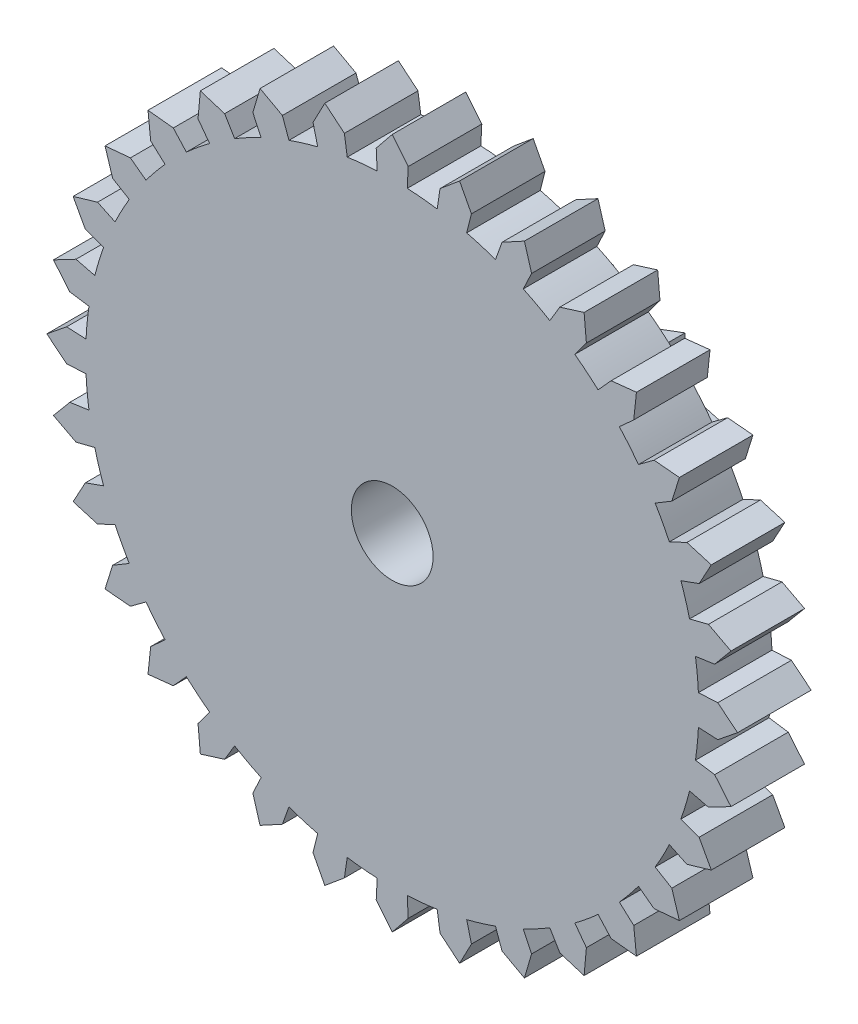
from build123d import *

# Parameters (mm, degrees)
SKETCH1_R           = 1
BOSS_EXTRUDE1_DEPTH = 1.8
SKETCH2_R           = 1
BOSS_EXTRUDE2_DEPTH = 3.6


with BuildPart() as part:
    # Sketch1 → Boss-Extrude1 (new body)
    with BuildSketch(Plane.XY):
        with BuildLine():
            Line((1.937766935, 7.735999244), (1.648513221, 8.287635619))
            Line((1.648513221, 8.287635619), (1.170175534, 7.888682667))
            Line((1.170175534, 7.888682667), (1.100478558, 7.418823825))
            ThreePointArc((1.100478558, 7.418823825), (0.918080064, 7.443596509), (0.735128552, 7.46388545))
            ThreePointArc((0.735128552, 7.46388545), (0.551734227, 7.479678425), (0.368007557, 7.490965922))
            Line((0.368007557, 7.490965922), (0.391314703, 7.965393763))
            Line((0.391314703, 7.965393763), (0, 8.45))
            Line((0, 8.45), (-0.391314703, 7.965393763))
            Line((-0.391314703, 7.965393763), (-0.368007557, 7.490965922))
            ThreePointArc((-0.368007557, 7.490965922), (-0.551734227, 7.479678425), (-0.735128552, 7.46388545))
            ThreePointArc((-0.735128552, 7.46388545), (-0.918080064, 7.443596509), (-1.100478558, 7.418823825))
            Line((-1.100478558, 7.418823825), (-1.170175534, 7.888682667))
            Line((-1.170175534, 7.888682667), (-1.648513221, 8.287635619))
            Line((-1.648513221, 8.287635619), (-1.937766935, 7.735999244))
            Line((-1.937766935, 7.735999244), (-1.822351349, 7.275234399))
            ThreePointArc((-1.822351349, 7.275234399), (-2.000345681, 7.228320493), (-2.177135079, 7.177052518))
            ThreePointArc((-2.177135079, 7.177052518), (-2.352613053, 7.121461354), (-2.5266739, 7.061580489))
            Line((-2.5266739, 7.061580489), (-2.686696581, 7.50881392))
            Line((-2.686696581, 7.50881392), (-3.233675003, 7.80678205))
            Line((-3.233675003, 7.80678205), (-3.40975187, 7.209314613))
            Line((-3.40975187, 7.209314613), (-3.206663201, 6.779919698))
            ThreePointArc((-3.206663201, 6.779919698), (-3.372084972, 6.699182259), (-3.535475526, 6.614409483))
            ThreePointArc((-3.535475526, 6.614409483), (-3.696736442, 6.525652433), (-3.855770581, 6.432964575))
            Line((-3.855770581, 6.432964575), (-4.099969385, 6.840385665))
            Line((-4.099969385, 6.840385665), (-4.694568469, 7.025918224))
            Line((-4.694568469, 7.025918224), (-4.750701953, 6.405580064))
            Line((-4.750701953, 6.405580064), (-4.467744784, 6.024056486))
            ThreePointArc((-4.467744784, 6.024056486), (-4.614236929, 5.912598207), (-4.757949631, 5.7975784))
            ThreePointArc((-4.757949631, 5.7975784), (-4.898796322, 5.679066349), (-5.036692161, 5.55713344))
            Line((-5.036692161, 5.55713344), (-5.355682665, 5.909085225))
            Line((-5.355682665, 5.909085225), (-5.975052301, 5.975052301))
            Line((-5.975052301, 5.975052301), (-5.909085225, 5.355682665))
            Line((-5.909085225, 5.355682665), (-5.55713344, 5.036692161))
            ThreePointArc((-5.55713344, 5.036692161), (-5.679066349, 4.898796322), (-5.7975784, 4.757949631))
            ThreePointArc((-5.7975784, 4.757949631), (-5.912598207, 4.614236929), (-6.024056486, 4.467744784))
            Line((-6.024056486, 4.467744784), (-6.405580064, 4.750701953))
            Line((-6.405580064, 4.750701953), (-7.025918224, 4.694568469))
            Line((-7.025918224, 4.694568469), (-6.840385665, 4.099969385))
            Line((-6.840385665, 4.099969385), (-6.432964575, 3.855770581))
            ThreePointArc((-6.432964575, 3.855770581), (-6.525652433, 3.696736442), (-6.614409483, 3.535475526))
            ThreePointArc((-6.614409483, 3.535475526), (-6.699182259, 3.372084972), (-6.779919698, 3.206663201))
            Line((-6.779919698, 3.206663201), (-7.209314613, 3.40975187))
            Line((-7.209314613, 3.40975187), (-7.80678205, 3.233675003))
            Line((-7.80678205, 3.233675003), (-7.50881392, 2.686696581))
            Line((-7.50881392, 2.686696581), (-7.061580489, 2.5266739))
            ThreePointArc((-7.061580489, 2.5266739), (-7.121461354, 2.352613053), (-7.177052518, 2.177135079))
            ThreePointArc((-7.177052518, 2.177135079), (-7.228320493, 2.000345681), (-7.275234399, 1.822351349))
            Line((-7.275234399, 1.822351349), (-7.735999244, 1.937766935))
            Line((-7.735999244, 1.937766935), (-8.287635619, 1.648513221))
            Line((-8.287635619, 1.648513221), (-7.888682667, 1.170175534))
            Line((-7.888682667, 1.170175534), (-7.418823825, 1.100478558))
            ThreePointArc((-7.418823825, 1.100478558), (-7.443596509, 0.918080064), (-7.46388545, 0.735128552))
            ThreePointArc((-7.46388545, 0.735128552), (-7.479678425, 0.551734227), (-7.490965922, 0.368007557))
            Line((-7.490965922, 0.368007557), (-7.965393763, 0.391314703))
            Line((-7.965393763, 0.391314703), (-8.45, 0))
            Line((-8.45, 0), (-7.965393763, -0.391314703))
            Line((-7.965393763, -0.391314703), (-7.490965922, -0.368007557))
            ThreePointArc((-7.490965922, -0.368007557), (-7.479678425, -0.551734227), (-7.46388545, -0.735128552))
            ThreePointArc((-7.46388545, -0.735128552), (-7.443596509, -0.918080064), (-7.418823825, -1.100478558))
            Line((-7.418823825, -1.100478558), (-7.888682667, -1.170175534))
            Line((-7.888682667, -1.170175534), (-8.287635619, -1.648513221))
            Line((-8.287635619, -1.648513221), (-7.735999244, -1.937766935))
            Line((-7.735999244, -1.937766935), (-7.275234399, -1.822351349))
            ThreePointArc((-7.275234399, -1.822351349), (-7.228320493, -2.000345681), (-7.177052518, -2.177135079))
            ThreePointArc((-7.177052518, -2.177135079), (-7.121461354, -2.352613053), (-7.061580489, -2.5266739))
            Line((-7.061580489, -2.5266739), (-7.50881392, -2.686696581))
            Line((-7.50881392, -2.686696581), (-7.80678205, -3.233675003))
            Line((-7.80678205, -3.233675003), (-7.209314613, -3.40975187))
            Line((-7.209314613, -3.40975187), (-6.779919698, -3.206663201))
            ThreePointArc((-6.779919698, -3.206663201), (-6.699182259, -3.372084972), (-6.614409483, -3.535475526))
            ThreePointArc((-6.614409483, -3.535475526), (-6.525652433, -3.696736442), (-6.432964575, -3.855770581))
            Line((-6.432964575, -3.855770581), (-6.840385665, -4.099969385))
            Line((-6.840385665, -4.099969385), (-7.025918224, -4.694568469))
            Line((-7.025918224, -4.694568469), (-6.405580064, -4.750701953))
            Line((-6.405580064, -4.750701953), (-6.024056486, -4.467744784))
            ThreePointArc((-6.024056486, -4.467744784), (-5.912598207, -4.614236929), (-5.7975784, -4.757949631))
            ThreePointArc((-5.7975784, -4.757949631), (-5.679066349, -4.898796322), (-5.55713344, -5.036692161))
            Line((-5.55713344, -5.036692161), (-5.909085225, -5.355682665))
            Line((-5.909085225, -5.355682665), (-5.975052301, -5.975052301))
            Line((-5.975052301, -5.975052301), (-5.355682665, -5.909085225))
            Line((-5.355682665, -5.909085225), (-5.036692161, -5.55713344))
            ThreePointArc((-5.036692161, -5.55713344), (-4.898796322, -5.679066349), (-4.757949631, -5.7975784))
            ThreePointArc((-4.757949631, -5.7975784), (-4.614236929, -5.912598207), (-4.467744784, -6.024056486))
            Line((-4.467744784, -6.024056486), (-4.750701953, -6.405580064))
            Line((-4.750701953, -6.405580064), (-4.694568469, -7.025918224))
            Line((-4.694568469, -7.025918224), (-4.099969385, -6.840385665))
            Line((-4.099969385, -6.840385665), (-3.855770581, -6.432964575))
            ThreePointArc((-3.855770581, -6.432964575), (-3.696736442, -6.525652433), (-3.535475526, -6.614409483))
            ThreePointArc((-3.535475526, -6.614409483), (-3.372084972, -6.699182259), (-3.206663201, -6.779919698))
            Line((-3.206663201, -6.779919698), (-3.40975187, -7.209314613))
            Line((-3.40975187, -7.209314613), (-3.233675003, -7.80678205))
            Line((-3.233675003, -7.80678205), (-2.686696581, -7.50881392))
            Line((-2.686696581, -7.50881392), (-2.5266739, -7.061580489))
            ThreePointArc((-2.5266739, -7.061580489), (-2.352613053, -7.121461354), (-2.177135079, -7.177052518))
            ThreePointArc((-2.177135079, -7.177052518), (-2.000345681, -7.228320493), (-1.822351349, -7.275234399))
            Line((-1.822351349, -7.275234399), (-1.937766935, -7.735999244))
            Line((-1.937766935, -7.735999244), (-1.648513221, -8.287635619))
            Line((-1.648513221, -8.287635619), (-1.170175534, -7.888682667))
            Line((-1.170175534, -7.888682667), (-1.100478558, -7.418823825))
            ThreePointArc((-1.100478558, -7.418823825), (-0.918080064, -7.443596509), (-0.735128552, -7.46388545))
            ThreePointArc((-0.735128552, -7.46388545), (-0.551734227, -7.479678425), (-0.368007557, -7.490965922))
            Line((-0.368007557, -7.490965922), (-0.391314703, -7.965393763))
            Line((-0.391314703, -7.965393763), (0, -8.45))
            Line((0, -8.45), (0.391314703, -7.965393763))
            Line((0.391314703, -7.965393763), (0.368007557, -7.490965922))
            ThreePointArc((0.368007557, -7.490965922), (0.551734227, -7.479678425), (0.735128552, -7.46388545))
            ThreePointArc((0.735128552, -7.46388545), (0.918080064, -7.443596509), (1.100478558, -7.418823825))
            Line((1.100478558, -7.418823825), (1.170175534, -7.888682667))
            Line((1.170175534, -7.888682667), (1.648513221, -8.287635619))
            Line((1.648513221, -8.287635619), (1.937766935, -7.735999244))
            Line((1.937766935, -7.735999244), (1.822351349, -7.275234399))
            ThreePointArc((1.822351349, -7.275234399), (2.000345681, -7.228320493), (2.177135079, -7.177052518))
            ThreePointArc((2.177135079, -7.177052518), (2.352613053, -7.121461354), (2.5266739, -7.061580489))
            Line((2.5266739, -7.061580489), (2.686696581, -7.50881392))
            Line((2.686696581, -7.50881392), (3.233675003, -7.80678205))
            Line((3.233675003, -7.80678205), (3.40975187, -7.209314613))
            Line((3.40975187, -7.209314613), (3.206663201, -6.779919698))
            ThreePointArc((3.206663201, -6.779919698), (3.372084972, -6.699182259), (3.535475526, -6.614409483))
            ThreePointArc((3.535475526, -6.614409483), (3.696736442, -6.525652433), (3.855770581, -6.432964575))
            Line((3.855770581, -6.432964575), (4.099969385, -6.840385665))
            Line((4.099969385, -6.840385665), (4.694568469, -7.025918224))
            Line((4.694568469, -7.025918224), (4.750701953, -6.405580064))
            Line((4.750701953, -6.405580064), (4.467744784, -6.024056486))
            ThreePointArc((4.467744784, -6.024056486), (4.614236929, -5.912598207), (4.757949631, -5.7975784))
            ThreePointArc((4.757949631, -5.7975784), (4.898796322, -5.679066349), (5.036692161, -5.55713344))
            Line((5.036692161, -5.55713344), (5.355682665, -5.909085225))
            Line((5.355682665, -5.909085225), (5.975052301, -5.975052301))
            Line((5.975052301, -5.975052301), (5.909085225, -5.355682665))
            Line((5.909085225, -5.355682665), (5.55713344, -5.036692161))
            ThreePointArc((5.55713344, -5.036692161), (5.679066349, -4.898796322), (5.7975784, -4.757949631))
            ThreePointArc((5.7975784, -4.757949631), (5.912598207, -4.614236929), (6.024056486, -4.467744784))
            Line((6.024056486, -4.467744784), (6.405580064, -4.750701953))
            Line((6.405580064, -4.750701953), (7.025918224, -4.694568469))
            Line((7.025918224, -4.694568469), (6.840385665, -4.099969385))
            Line((6.840385665, -4.099969385), (6.432964575, -3.855770581))
            ThreePointArc((6.432964575, -3.855770581), (6.525652433, -3.696736442), (6.614409483, -3.535475526))
            ThreePointArc((6.614409483, -3.535475526), (6.699182259, -3.372084972), (6.779919698, -3.206663201))
            Line((6.779919698, -3.206663201), (7.209314613, -3.40975187))
            Line((7.209314613, -3.40975187), (7.80678205, -3.233675003))
            Line((7.80678205, -3.233675003), (7.50881392, -2.686696581))
            Line((7.50881392, -2.686696581), (7.061580489, -2.5266739))
            ThreePointArc((7.061580489, -2.5266739), (7.121461354, -2.352613053), (7.177052518, -2.177135079))
            ThreePointArc((7.177052518, -2.177135079), (7.228320493, -2.000345681), (7.275234399, -1.822351349))
            Line((7.275234399, -1.822351349), (7.735999244, -1.937766935))
            Line((7.735999244, -1.937766935), (8.287635619, -1.648513221))
            Line((8.287635619, -1.648513221), (7.888682667, -1.170175534))
            Line((7.888682667, -1.170175534), (7.418823825, -1.100478558))
            ThreePointArc((7.418823825, -1.100478558), (7.443596509, -0.918080064), (7.46388545, -0.735128552))
            ThreePointArc((7.46388545, -0.735128552), (7.479678425, -0.551734227), (7.490965922, -0.368007557))
            Line((7.490965922, -0.368007557), (7.965393763, -0.391314703))
            Line((7.965393763, -0.391314703), (8.45, 0))
            Line((8.45, 0), (7.965393763, 0.391314703))
            Line((7.965393763, 0.391314703), (7.490965922, 0.368007557))
            ThreePointArc((7.490965922, 0.368007557), (7.479678425, 0.551734227), (7.46388545, 0.735128552))
            ThreePointArc((7.46388545, 0.735128552), (7.443596509, 0.918080064), (7.418823825, 1.100478558))
            Line((7.418823825, 1.100478558), (7.888682667, 1.170175534))
            Line((7.888682667, 1.170175534), (8.287635619, 1.648513221))
            Line((8.287635619, 1.648513221), (7.735999244, 1.937766935))
            Line((7.735999244, 1.937766935), (7.275234399, 1.822351349))
            ThreePointArc((7.275234399, 1.822351349), (7.228320493, 2.000345681), (7.177052518, 2.177135079))
            ThreePointArc((7.177052518, 2.177135079), (7.121461354, 2.352613053), (7.061580489, 2.5266739))
            Line((7.061580489, 2.5266739), (7.50881392, 2.686696581))
            Line((7.50881392, 2.686696581), (7.80678205, 3.233675003))
            Line((7.80678205, 3.233675003), (7.209314613, 3.40975187))
            Line((7.209314613, 3.40975187), (6.779919698, 3.206663201))
            ThreePointArc((6.779919698, 3.206663201), (6.699182259, 3.372084972), (6.614409483, 3.535475526))
            ThreePointArc((6.614409483, 3.535475526), (6.525652433, 3.696736442), (6.432964575, 3.855770581))
            Line((6.432964575, 3.855770581), (6.840385665, 4.099969385))
            Line((6.840385665, 4.099969385), (7.025918224, 4.694568469))
            Line((7.025918224, 4.694568469), (6.405580064, 4.750701953))
            Line((6.405580064, 4.750701953), (6.024056486, 4.467744784))
            ThreePointArc((6.024056486, 4.467744784), (5.912598207, 4.614236929), (5.7975784, 4.757949631))
            ThreePointArc((5.7975784, 4.757949631), (5.679066349, 4.898796322), (5.55713344, 5.036692161))
            Line((5.55713344, 5.036692161), (5.909085225, 5.355682665))
            Line((5.909085225, 5.355682665), (5.975052301, 5.975052301))
            Line((5.975052301, 5.975052301), (5.355682665, 5.909085225))
            Line((5.355682665, 5.909085225), (5.036692161, 5.55713344))
            ThreePointArc((5.036692161, 5.55713344), (4.898796322, 5.679066349), (4.757949631, 5.7975784))
            ThreePointArc((4.757949631, 5.7975784), (4.614236929, 5.912598207), (4.467744784, 6.024056486))
            Line((4.467744784, 6.024056486), (4.750701953, 6.405580064))
            Line((4.750701953, 6.405580064), (4.694568469, 7.025918224))
            Line((4.694568469, 7.025918224), (4.099969385, 6.840385665))
            Line((4.099969385, 6.840385665), (3.855770581, 6.432964575))
            ThreePointArc((3.855770581, 6.432964575), (3.696736442, 6.525652433), (3.535475526, 6.614409483))
            ThreePointArc((3.535475526, 6.614409483), (3.372084972, 6.699182259), (3.206663201, 6.779919698))
            Line((3.206663201, 6.779919698), (3.40975187, 7.209314613))
            Line((3.40975187, 7.209314613), (3.233675003, 7.80678205))
            Line((3.233675003, 7.80678205), (2.686696581, 7.50881392))
            Line((2.686696581, 7.50881392), (2.5266739, 7.061580489))
            ThreePointArc((2.5266739, 7.061580489), (2.352613053, 7.121461354), (2.177135079, 7.177052518))
            ThreePointArc((2.177135079, 7.177052518), (2.000345681, 7.228320493), (1.822351349, 7.275234399))
            Line((1.822351349, 7.275234399), (1.937766935, 7.735999244))
        make_face()
        Circle(SKETCH1_R, mode=Mode.SUBTRACT)
    extrude(amount=BOSS_EXTRUDE1_DEPTH)

    # Sketch2 → Boss-Extrude2 (add)
    with BuildSketch(Plane.XY):
        with BuildLine():
            Line((1.734868093, 1.780384535), (1.763355757, 2.427050983))
            Line((1.763355757, 2.427050983), (1.15714259, 2.200126682))
            Line((1.15714259, 2.200126682), (0.907702524, 1.725855188))
            ThreePointArc((0.907702524, 1.725855188), (0.757879899, 1.796696429), (0.602583139, 1.854560207))
            ThreePointArc((0.602583139, 1.854560207), (0.442933946, 1.899028573), (0.28008546, 1.929780333))
            Line((0.28008546, 1.929780333), (0.357053997, 2.460091225))
            Line((0.357053997, 2.460091225), (0, 3))
            Line((0, 3), (-0.357053997, 2.460091225))
            Line((-0.357053997, 2.460091225), (-0.28008546, 1.929780333))
            ThreePointArc((-0.28008546, 1.929780333), (-0.442933946, 1.899028573), (-0.602583139, 1.854560207))
            ThreePointArc((-0.602583139, 1.854560207), (-0.757879899, 1.796696429), (-0.907702524, 1.725855188))
            Line((-0.907702524, 1.725855188), (-1.15714259, 2.200126682))
            Line((-1.15714259, 2.200126682), (-1.763355757, 2.427050983))
            Line((-1.763355757, 2.427050983), (-1.734868093, 1.780384535))
            Line((-1.734868093, 1.780384535), (-1.360890317, 1.396594983))
            ThreePointArc((-1.360890317, 1.396594983), (-1.474562078, 1.275996347), (-1.577583139, 1.146181242))
            ThreePointArc((-1.577583139, 1.146181242), (-1.669209382, 1.008087317), (-1.748778994, 0.86271202))
            Line((-1.748778994, 0.86271202), (-2.229350037, 1.099788527))
            Line((-2.229350037, 1.099788527), (-2.853169549, 0.927050983))
            Line((-2.853169549, 0.927050983), (-2.450021543, 0.420631466))
            Line((-2.450021543, 0.420631466), (-1.921881328, 0.329957817))
            ThreePointArc((-1.921881328, 0.329957817), (-1.942957615, 0.165576886), (-1.95, 0))
            ThreePointArc((-1.95, 0), (-1.942957615, -0.165576886), (-1.921881328, -0.329957817))
            Line((-1.921881328, -0.329957817), (-2.450021543, -0.420631466))
            Line((-2.450021543, -0.420631466), (-2.853169549, -0.927050983))
            Line((-2.853169549, -0.927050983), (-2.229350037, -1.099788527))
            Line((-2.229350037, -1.099788527), (-1.748778994, -0.86271202))
            ThreePointArc((-1.748778994, -0.86271202), (-1.669209382, -1.008087317), (-1.577583139, -1.146181242))
            ThreePointArc((-1.577583139, -1.146181242), (-1.474562078, -1.275996347), (-1.360890317, -1.396594983))
            Line((-1.360890317, -1.396594983), (-1.734868093, -1.780384535))
            Line((-1.734868093, -1.780384535), (-1.763355757, -2.427050983))
            Line((-1.763355757, -2.427050983), (-1.15714259, -2.200126682))
            Line((-1.15714259, -2.200126682), (-0.907702524, -1.725855188))
            ThreePointArc((-0.907702524, -1.725855188), (-0.757879899, -1.796696429), (-0.602583139, -1.854560207))
            ThreePointArc((-0.602583139, -1.854560207), (-0.442933946, -1.899028573), (-0.28008546, -1.929780333))
            Line((-0.28008546, -1.929780333), (-0.357053997, -2.460091225))
            Line((-0.357053997, -2.460091225), (0, -3))
            Line((0, -3), (0.357053997, -2.460091225))
            Line((0.357053997, -2.460091225), (0.28008546, -1.929780333))
            ThreePointArc((0.28008546, -1.929780333), (0.442933946, -1.899028573), (0.602583139, -1.854560207))
            ThreePointArc((0.602583139, -1.854560207), (0.757879899, -1.796696429), (0.907702524, -1.725855188))
            Line((0.907702524, -1.725855188), (1.15714259, -2.200126682))
            Line((1.15714259, -2.200126682), (1.763355757, -2.427050983))
            Line((1.763355757, -2.427050983), (1.734868093, -1.780384535))
            Line((1.734868093, -1.780384535), (1.360890317, -1.396594983))
            ThreePointArc((1.360890317, -1.396594983), (1.474562078, -1.275996347), (1.577583139, -1.146181242))
            ThreePointArc((1.577583139, -1.146181242), (1.669209382, -1.008087317), (1.748778994, -0.86271202))
            Line((1.748778994, -0.86271202), (2.229350037, -1.099788527))
            Line((2.229350037, -1.099788527), (2.853169549, -0.927050983))
            Line((2.853169549, -0.927050983), (2.450021543, -0.420631466))
            Line((2.450021543, -0.420631466), (1.921881328, -0.329957817))
            ThreePointArc((1.921881328, -0.329957817), (1.942957615, -0.165576886), (1.95, 0))
            ThreePointArc((1.95, 0), (1.942957615, 0.165576886), (1.921881328, 0.329957817))
            Line((1.921881328, 0.329957817), (2.450021543, 0.420631466))
            Line((2.450021543, 0.420631466), (2.853169549, 0.927050983))
            Line((2.853169549, 0.927050983), (2.229350037, 1.099788527))
            Line((2.229350037, 1.099788527), (1.748778994, 0.86271202))
            ThreePointArc((1.748778994, 0.86271202), (1.669209382, 1.008087317), (1.577583139, 1.146181242))
            ThreePointArc((1.577583139, 1.146181242), (1.474562078, 1.275996347), (1.360890317, 1.396594983))
            Line((1.360890317, 1.396594983), (1.734868093, 1.780384535))
        make_face()
        Circle(SKETCH2_R, mode=Mode.SUBTRACT)
    extrude(amount=-BOSS_EXTRUDE2_DEPTH)


solid = part.part
